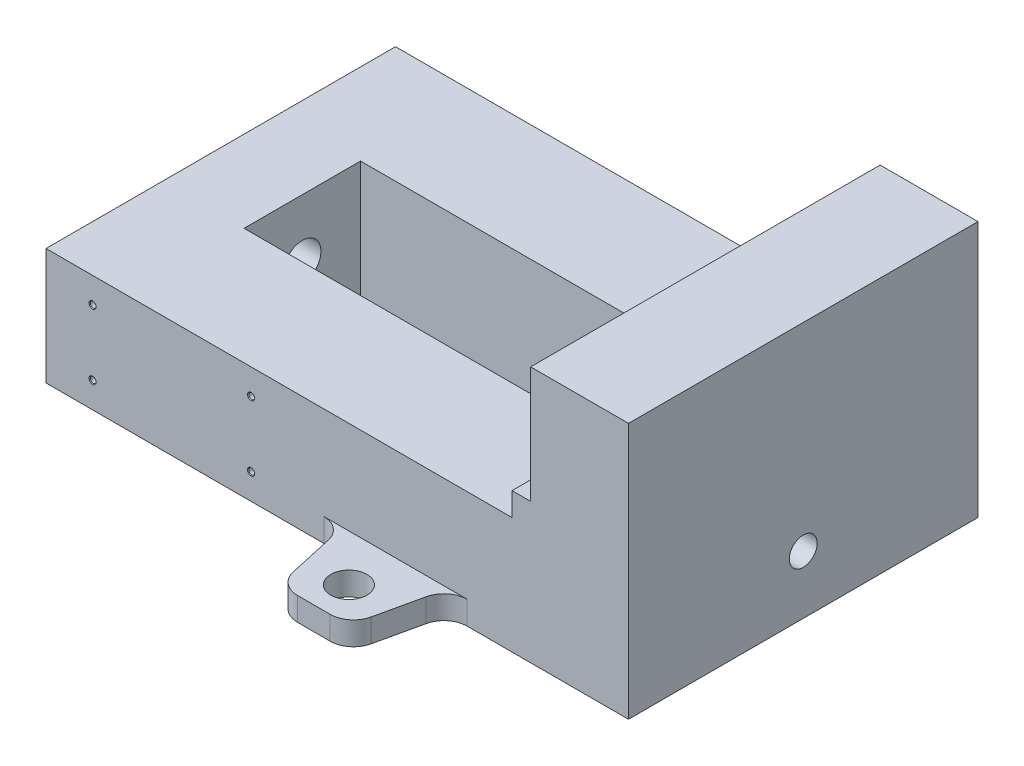
from build123d import *

# Parameters (mm, degrees)
BOSS_EXTRUDE2_DEPTH             = 75
CUT_EXTRUDE1_START              = -35
SKETCH3_W                       = 50
SKETCH3_H                       = 50
CUT_EXTRUDE1_DEPTH              = 165
SKETCH4_R                       = 14
BOSS_EXTRUDE3_DEPTH             = 5
CUT_EXTRUDE2_REACH              = 257
SKETCH5_R                       = 6
CUT_EXTRUDE2_DIRECTION_2_DEPTH  = 1
CUT_EXTRUDE4_REACH              = 257
SKETCH9_R                       = 8
FILLET2_R                       = 3
M6X1_0_TAPPED_HOLE2_D           = 5
M6X1_0_TAPPED_HOLE2_DEPTH       = 17.097848452
M6X1_0_TAPPED_HOLE2_CSINK_D     = 6.05
M6X1_0_TAPPED_HOLE2_CSINK_ANGLE = 90
M6X1_0_TAPPED_HOLE2_TIP         = 1.502151548
M3X0_5_TAPPED_HOLE1_D           = 2.5
M3X0_5_TAPPED_HOLE1_DEPTH       = 8.748924226
M3X0_5_TAPPED_HOLE1_CSINK_D     = 3.05
M3X0_5_TAPPED_HOLE1_CSINK_ANGLE = 90
M3X0_5_TAPPED_HOLE1_TIP         = 0.751075774
BOSS_EXTRUDE4_DEPTH             = 10
CUT_EXTRUDE5_START              = -11
SKETCH17_R                      = 7.75
CUT_EXTRUDE5_DEPTH              = 112
FILLET3_R                       = 10
FILLET4_R                       = 10


with BuildPart() as part:
    # Sketch1 → Boss-Extrude2 (new body, symmetric)
    with BuildSketch(Plane.XY):
        Polygon((0, 0), (250, 0), (250, 110), (208, 110), (208, 60), (200, 60), (200, 50), (0, 50), align=None)
    extrude(amount=BOSS_EXTRUDE2_DEPTH, both=True)

    # Sketch3 → Cut-Extrude1 (cut)
    with BuildSketch(Plane.ZY.offset(CUT_EXTRUDE1_START)):
        with Locations((0, 25)):
            Rectangle(SKETCH3_W, SKETCH3_H)
    extrude(amount=-CUT_EXTRUDE1_DEPTH, mode=Mode.SUBTRACT)

    # Sketch4 → Boss-Extrude3 (add)
    with BuildSketch(Plane.ZY):
        with Locations((0, 25)):
            Circle(SKETCH4_R)
    extrude(amount=BOSS_EXTRUDE3_DEPTH)

    # Sketch5 → Cut-Extrude2 (cut, up to next)
    with BuildSketch(Plane(origin=(250, 0, 0), x_dir=(0, 0, -1), z_dir=(1, 0, 0)), mode=Mode.PRIVATE) as cut_extrude2_sk1:
        with Locations((0, 25)):
            Circle(SKETCH5_R)
    cut_extrude2_tool1 = extrude(cut_extrude2_sk1.sketch, amount=-CUT_EXTRUDE2_REACH, mode=Mode.PRIVATE) & part.part
    add(cut_extrude2_tool1.solids().sort_by_distance((250, 25, 0))[0], mode=Mode.SUBTRACT)

    # Sketch5 → Cut-Extrude2 direction 2 (cut)
    with BuildSketch(Plane(origin=(250, 0, 0), x_dir=(0, 0, -1), z_dir=(1, 0, 0))):
        with Locations((0, 25)):
            Circle(SKETCH5_R)
    extrude(amount=CUT_EXTRUDE2_DIRECTION_2_DEPTH, mode=Mode.SUBTRACT)

    # Sketch9 → Cut-Extrude4 (cut, up to next)
    with BuildSketch(Plane.ZY.offset(5), mode=Mode.PRIVATE) as cut_extrude4_sk1:
        with Locations((0, 25)):
            Circle(SKETCH9_R)
    cut_extrude4_tool1 = extrude(cut_extrude4_sk1.sketch, amount=-CUT_EXTRUDE4_REACH, mode=Mode.PRIVATE) & part.part
    add(cut_extrude4_tool1.solids().sort_by_distance((-5, 25, 0))[0], mode=Mode.SUBTRACT)

    # Fillet2
    fillet2_edges = [part.edges().sort_by_distance(p)[0] for p in [
        (0, 25, -14),
    ]]
    fillet(fillet2_edges, radius=FILLET2_R)

    # M6x1.0 Tapped Hole2
    with Locations(Plane(origin=(208, 85, -45), x_dir=(0, 0, -1), z_dir=(-1, 0, 0))):
        with Locations((0, 0), (-90, 0)):
            CounterSinkHole(M6X1_0_TAPPED_HOLE2_D / 2, M6X1_0_TAPPED_HOLE2_CSINK_D / 2, depth=M6X1_0_TAPPED_HOLE2_DEPTH, counter_sink_angle=M6X1_0_TAPPED_HOLE2_CSINK_ANGLE)
            with Locations((0, 0, -(M6X1_0_TAPPED_HOLE2_DEPTH + M6X1_0_TAPPED_HOLE2_TIP / 2))):  # 118° drill point
                Cone(0, M6X1_0_TAPPED_HOLE2_D / 2, M6X1_0_TAPPED_HOLE2_TIP, mode=Mode.SUBTRACT)

    # M3x0.5 Tapped Hole1
    with Locations(Plane(origin=(20, 39, 75), x_dir=(1, 0, 0), z_dir=(0, 0, 1))):
        with Locations((0, 0), (68, 0), (68, -28), (0, -28)):
            CounterSinkHole(M3X0_5_TAPPED_HOLE1_D / 2, M3X0_5_TAPPED_HOLE1_CSINK_D / 2, depth=M3X0_5_TAPPED_HOLE1_DEPTH, counter_sink_angle=M3X0_5_TAPPED_HOLE1_CSINK_ANGLE)
            with Locations((0, 0, -(M3X0_5_TAPPED_HOLE1_DEPTH + M3X0_5_TAPPED_HOLE1_TIP / 2))):  # 118° drill point
                Cone(0, M3X0_5_TAPPED_HOLE1_D / 2, M3X0_5_TAPPED_HOLE1_TIP, mode=Mode.SUBTRACT)

    # Sketch15 → Boss-Extrude4 (add)
    with BuildSketch(Plane(origin=(0, 0, 0), x_dir=(1, 0, 0), z_dir=(0, 1, 0))):
        Polygon((127.240686807, -75), (172.759313193, -75), (165, -110), (135, -110), align=None)
    boss_extrude4 = extrude(amount=BOSS_EXTRUDE4_DEPTH)

    # Sketch17 → Cut-Extrude5 (cut)
    with BuildSketch(Plane(origin=(0, 10, 0), x_dir=(1, 0, 0), z_dir=(0, 1, 0)).offset(CUT_EXTRUDE5_START)):
        with Locations((150, -95)):
            Circle(SKETCH17_R)
    cut_extrude5 = extrude(amount=CUT_EXTRUDE5_DEPTH, mode=Mode.SUBTRACT)

    # Fillet3
    fillet3_edges = [part.edges().sort_by_distance(p)[0] for p in [
        (135, 5, 110),
        (165, 5, 110),
        (172.759313193, 5, 75),
        (127.240686807, 5, 75),
    ]]
    fillet(fillet3_edges, radius=FILLET3_R)

    # Mirror3: Boss-Extrude4, Cut-Extrude5 across plane
    add(boss_extrude4.mirror(Plane.XY))
    add(cut_extrude5.mirror(Plane.XY), mode=Mode.SUBTRACT)

    # Fillet4
    fillet4_edges = [part.edges().sort_by_distance(p)[0] for p in [
        (165, 5, -110),
        (135, 5, -110),
        (127.240686807, 5, -75),
        (172.759313193, 5, -75),
    ]]
    fillet(fillet4_edges, radius=FILLET4_R)


solid = part.part
